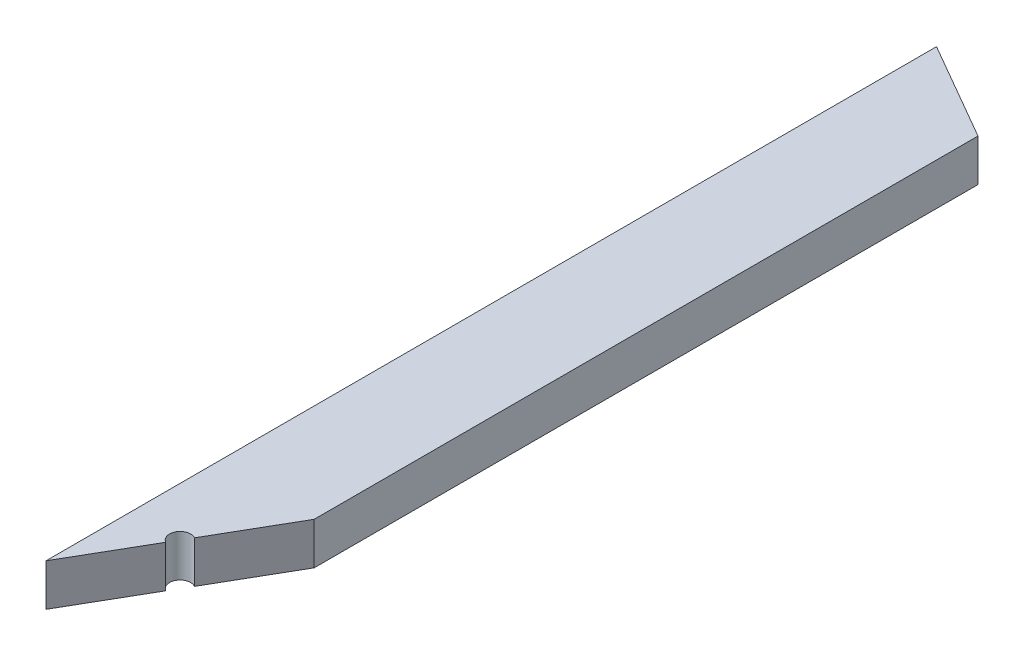
from build123d import *

# Parameters (mm, degrees)
SKETCH1_W           = 88.9
SKETCH1_H           = 38.1
BOSS_EXTRUDE1_DEPTH = 806.55922
CUT_EXTRUDE1_DEPTH  = 39.1
SKETCH3_R           = 9.525
CUT_EXTRUDE2_DEPTH  = 39.1


with BuildPart() as part:
    # Sketch1 → Boss-Extrude1 (new body)
    with BuildSketch(Plane.XY):
        Rectangle(SKETCH1_W, SKETCH1_H)
    extrude(amount=BOSS_EXTRUDE1_DEPTH)

    # Sketch2 → Cut-Extrude1 (cut, through all)
    with BuildSketch(Plane(origin=(0, 19.05, 0), x_dir=(1, 0, 0), z_dir=(0, 1, 0))):
        Polygon((-44.45, 0), (44.45, 0), (44.45, -51.326438931), align=None)
        Polygon((-44.45, -806.55922), (44.45, -652.579903207), (44.45, -806.55922), align=None)
    extrude(amount=-CUT_EXTRUDE1_DEPTH, mode=Mode.SUBTRACT)

    # Sketch3 → Cut-Extrude2 (cut, through all)
    with BuildSketch(Plane(origin=(0, 19.05, 0), x_dir=(1, 0, 0), z_dir=(0, 1, 0))):
        with Locations((0, -729.569561604)):
            Circle(SKETCH3_R)
    extrude(amount=-CUT_EXTRUDE2_DEPTH, mode=Mode.SUBTRACT)


solid = part.part
